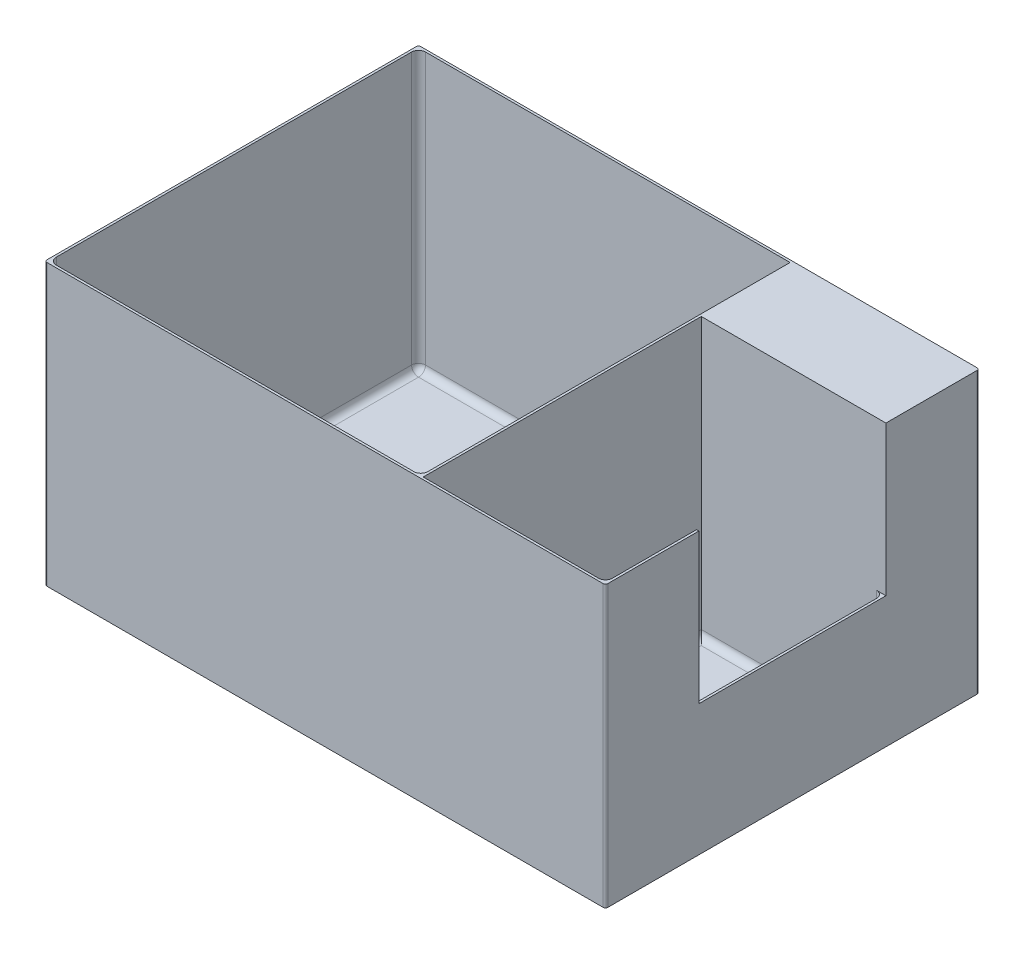
from build123d import *

# Parameters (mm, degrees)
SKETCH_1_W          = 240
SKETCH_1_H          = 160
EXTRUDE_1_DEPTH     = 120
SKETCH_2_W          = 159
SKETCH_2_H          = 158
SKETCH_2_W_2        = 78
SKETCH_2_H_2        = 119
CUT_EXTRUDE_1_DEPTH = 119
CUT_EXTRUDE_2_REACH = 242
SKETCH_3_W          = 80
SKETCH_3_H          = 64
FILLET_1_R          = 1
FILLET_2_R          = 3


with BuildPart() as part:
    # 草圖1 → 填料-伸長1 (new body)
    with BuildSketch(Plane(origin=(0, 0, 0), x_dir=(1, 0, 0), z_dir=(0, 1, 0))):
        Rectangle(SKETCH_1_W, SKETCH_1_H)
    extrude(amount=EXTRUDE_1_DEPTH)

    # 草圖2 → 除料-伸長1 (cut)
    with BuildSketch(Plane(origin=(0, 120, 0), x_dir=(1, 0, 0), z_dir=(0, 1, 0))):
        with Locations((-39.5, 0)):
            Rectangle(SKETCH_2_W, SKETCH_2_H)
        with Locations((80, -19.5)):
            Rectangle(SKETCH_2_W_2, SKETCH_2_H_2)
    extrude(amount=-CUT_EXTRUDE_1_DEPTH, mode=Mode.SUBTRACT)

    # 草圖3 → 除料-伸長2 (cut, up to next)
    with BuildSketch(Plane(origin=(120, 0, 0), x_dir=(0, 0, -1), z_dir=(1, 0, 0)), mode=Mode.PRIVATE) as cut_extrude_2_sk1:
        with Locations((0, 88)):
            Rectangle(SKETCH_3_W, SKETCH_3_H)
    cut_extrude_2_tool1 = extrude(cut_extrude_2_sk1.sketch, amount=-CUT_EXTRUDE_2_REACH, mode=Mode.PRIVATE) & part.part
    add(cut_extrude_2_tool1.solids().sort_by_distance((120, 88, 0))[0], mode=Mode.SUBTRACT)

    # 圓角1
    fillet_1_edges = [part.edges().sort_by_distance(p)[0] for p in [
        (120, 60, 80),
        (-120, 60, 80),
        (-120, 60, -80),
        (120, 60, -80),
    ]]
    fillet(fillet_1_edges, radius=FILLET_1_R)

    # 圓角2
    fillet_2_edges = [part.edges().sort_by_distance(p)[0] for p in [
        (40, 1, 0),
        (-39.5, 1, 79),
        (40, 60.5, 79),
        (-119, 1, 0),
        (-119, 60.5, 79),
        (-39.5, 1, -79),
        (-119, 60.5, -79),
        (119, 1, 19.5),
        (119, 28.5, -40),
        (80, 1, 79),
        (119, 60.5, 79),
        (41, 1, 19.5),
        (80, 1, -40),
    ]]
    fillet(fillet_2_edges, radius=FILLET_2_R)


solid = part.part
